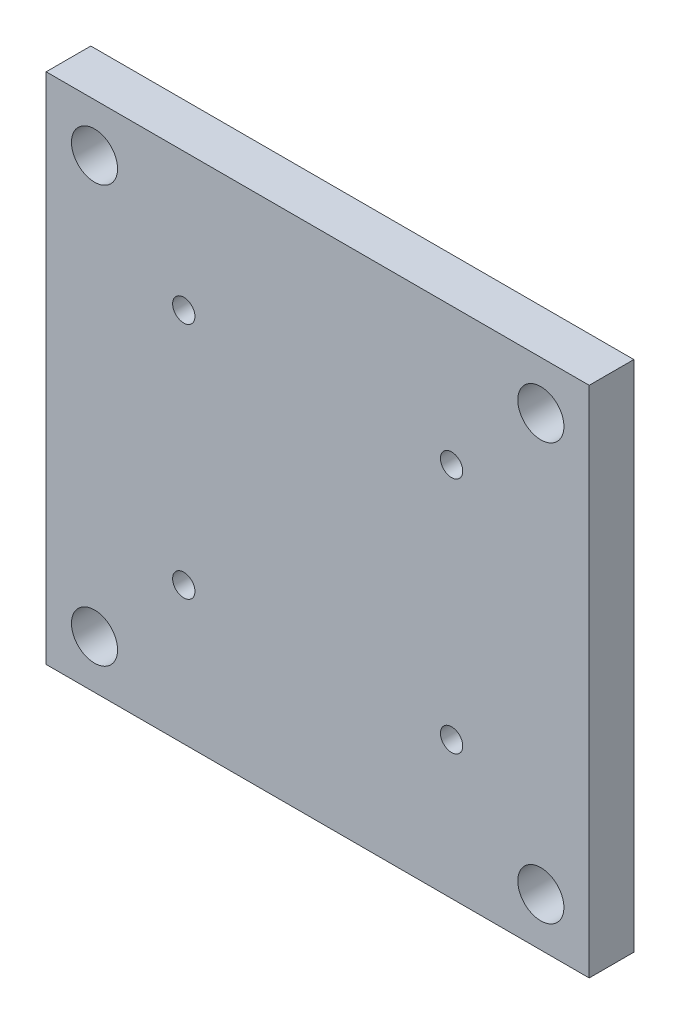
from build123d import *

# Parameters (mm, degrees)
CROQUIS1_W              = 73
CROQUIS1_H              = 69
CROQUIS1_R              = 3.1
CROQUIS1_R_2            = 1.5
SALIENTE_EXTRUIR1_DEPTH = 6
CROQUIS2_R              = 2.75
CORTAR_EXTRUIR1_DEPTH   = 3


with BuildPart() as part:
    # Croquis1 → Saliente-Extruir1 (new body)
    with BuildSketch(Plane.XY):
        with Locations((36.5, 34.5)):
            Rectangle(CROQUIS1_W, CROQUIS1_H)
        with Locations((6.5, 6.5)):
            Circle(CROQUIS1_R, mode=Mode.SUBTRACT)
        with Locations((66.5, 6.5)):
            Circle(CROQUIS1_R, mode=Mode.SUBTRACT)
        with Locations((66.5, 62.5)):
            Circle(CROQUIS1_R, mode=Mode.SUBTRACT)
        with Locations((6.5, 62.5)):
            Circle(CROQUIS1_R, mode=Mode.SUBTRACT)
        with Locations((18.5, 50.5)):
            Circle(CROQUIS1_R_2, mode=Mode.SUBTRACT)
        with Locations((54.5, 50.5)):
            Circle(CROQUIS1_R_2, mode=Mode.SUBTRACT)
        with Locations((54.5, 18.5)):
            Circle(CROQUIS1_R_2, mode=Mode.SUBTRACT)
        with Locations((18.5, 18.5)):
            Circle(CROQUIS1_R_2, mode=Mode.SUBTRACT)
    extrude(amount=SALIENTE_EXTRUIR1_DEPTH)

    # Croquis2 → Cortar-Extruir1 (cut)
    with BuildSketch(Plane(origin=(0, 0, 0), x_dir=(-1, 0, 0), z_dir=(0, 0, -1))):
        with Locations((-54.5, 50.5)):
            Circle(CROQUIS2_R)
        with Locations((-18.5, 50.5)):
            Circle(CROQUIS2_R)
        with Locations((-18.5, 18.5)):
            Circle(CROQUIS2_R)
        with Locations((-54.5, 18.5)):
            Circle(CROQUIS2_R)
    extrude(amount=-CORTAR_EXTRUIR1_DEPTH, mode=Mode.SUBTRACT)


solid = part.part
